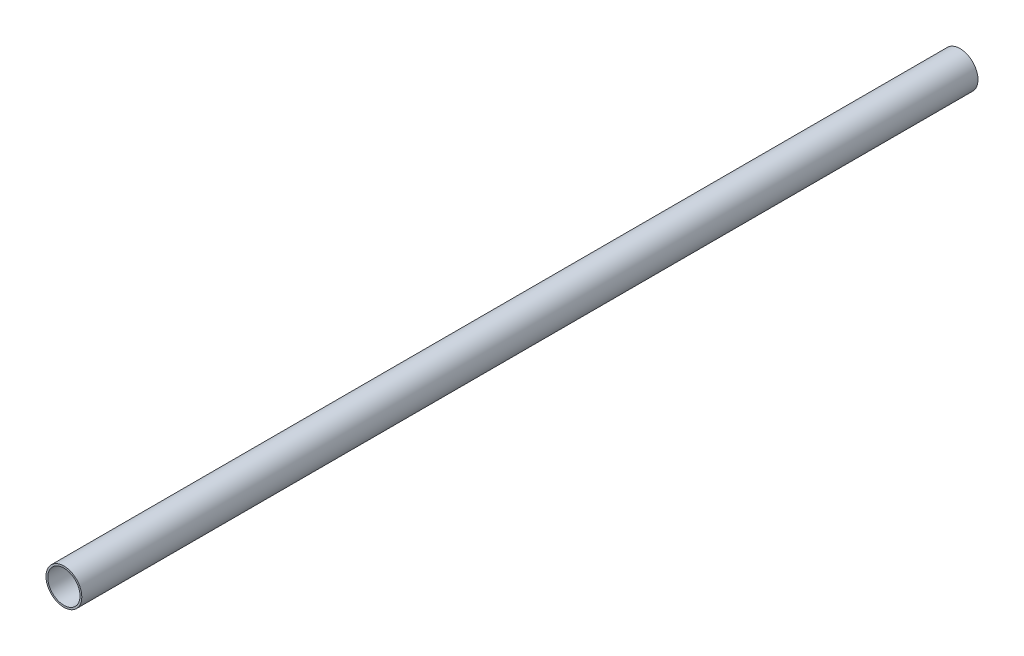
from build123d import *

# Parameters (mm, degrees)
SKETCH1_R           = 10
SKETCH1_R_2         = 9
BOSS_EXTRUDE1_DEPTH = 500


with BuildPart() as part:
    # Sketch1 → Boss-Extrude1 (new body)
    with BuildSketch(Plane.XY):
        Circle(SKETCH1_R)
        Circle(SKETCH1_R_2, mode=Mode.SUBTRACT)
    extrude(amount=BOSS_EXTRUDE1_DEPTH)


solid = part.part
